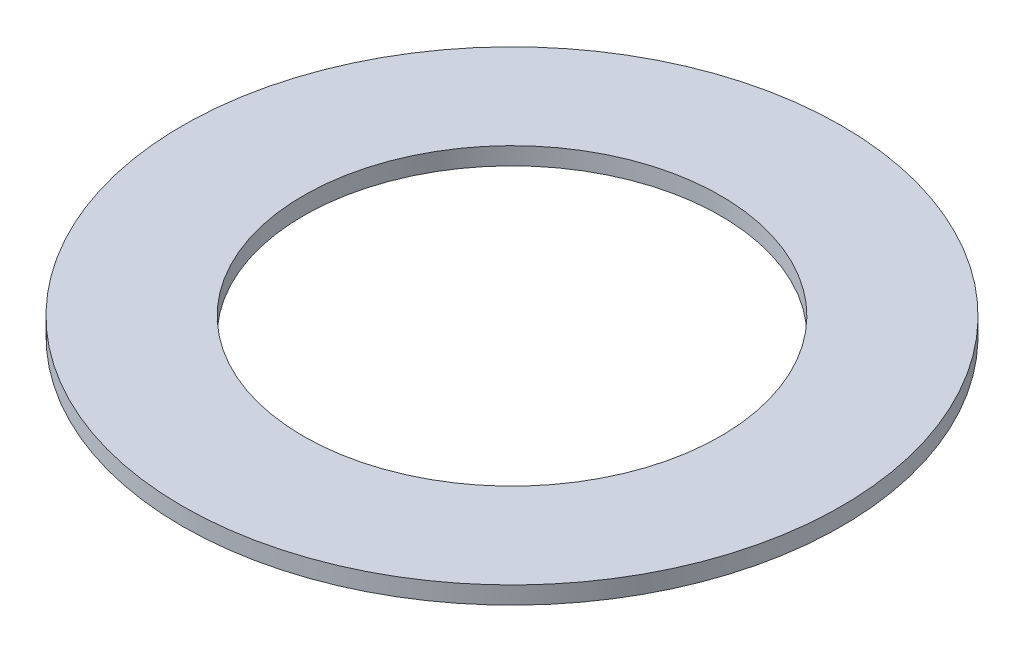
from build123d import *

# Parameters (mm, degrees)
SKETCH1_R           = 5.65
SKETCH1_R_2         = 3.575
BOSS_EXTRUDE1_DEPTH = 0.3


with BuildPart() as part:
    # Sketch1 → Boss-Extrude1 (new body)
    with BuildSketch(Plane(origin=(0, 0, 0), x_dir=(1, 0, 0), z_dir=(0, 1, 0))):
        Circle(SKETCH1_R)
        Circle(SKETCH1_R_2, mode=Mode.SUBTRACT)
    extrude(amount=BOSS_EXTRUDE1_DEPTH)


solid = part.part
